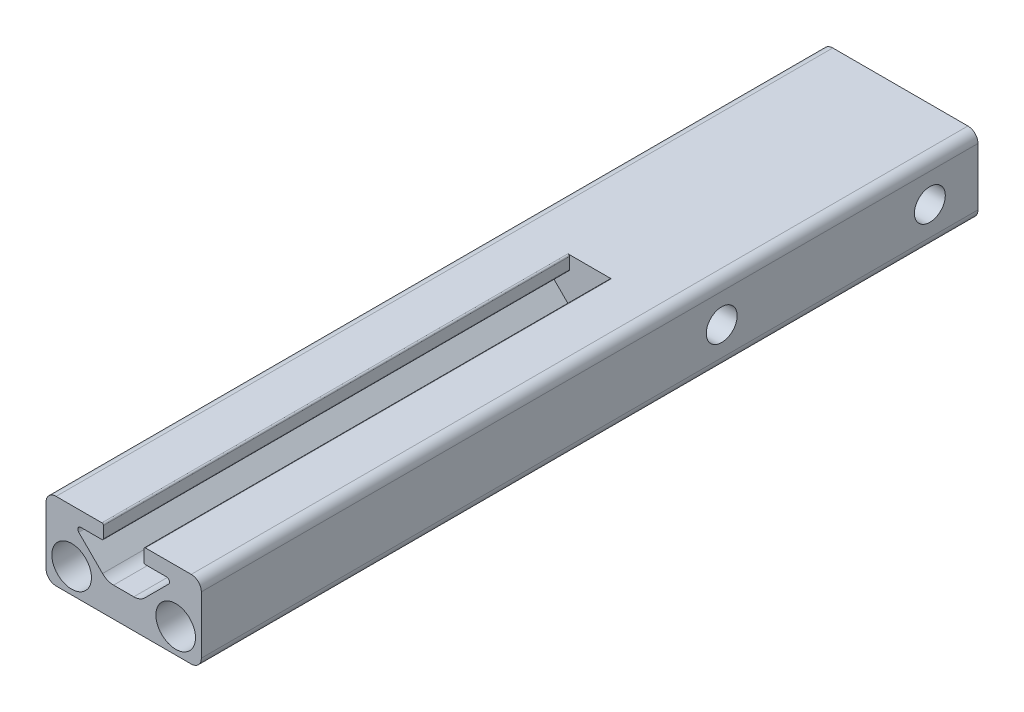
from build123d import *

# Parameters (mm, degrees)
SKETCH3_R                  = 3.2385
BOSS_EXTRUDE1_DEPTH        = 38.1
FILLET1_R                  = 0.254
BOSS_EXTRUDE2_DEPTH        = 50.8
F_8_0_199_DIAMETER_HOLE8_D = 5.0546
LPATTERN1_COUNT            = 2
LPATTERN1_PITCH            = 34.036


with BuildPart() as part:
    # Sketch3 → Boss-Extrude1 (new body, symmetric)
    with BuildSketch(Plane.XY):
        with BuildLine():
            Line((-11.049, 12.7), (-3.302, 12.7))
            Line((-3.302, 12.7), (-3.302, 10.328863887))
            Line((-3.302, 10.328863887), (-6.985, 10.328863887))
            ThreePointArc((-6.985, 10.328863887), (-7.454330803, 10.01526707), (-7.344210245, 9.461653642))
            Line((-7.344210245, 9.461653642), (-3.452505379, 5.569948776))
            ThreePointArc((-3.452505379, 5.569948776), (-2.628470073, 5.019345987), (-1.656454155, 4.826))
            Line((-1.656454155, 4.826), (1.656454155, 4.826))
            ThreePointArc((1.656454155, 4.826), (2.628470073, 5.019345987), (3.452505379, 5.569948776))
            Line((3.452505379, 5.569948776), (7.344210245, 9.461653642))
            ThreePointArc((7.344210245, 9.461653642), (7.454330803, 10.01526707), (6.985, 10.328863887))
            Line((6.985, 10.328863887), (3.302, 10.328863887))
            Line((3.302, 10.328863887), (3.302, 12.7))
            Line((3.302, 12.7), (11.049, 12.7))
            ThreePointArc((11.049, 12.7), (12.216433296, 12.216433296), (12.7, 11.049))
            Line((12.7, 11.049), (12.7, 1.651))
            ThreePointArc((12.7, 1.651), (12.216433296, 0.483566704), (11.049, 0))
            Line((11.049, 0), (-11.049, 0))
            ThreePointArc((-11.049, 0), (-12.216433296, 0.483566704), (-12.7, 1.651))
            Line((-12.7, 1.651), (-12.7, 11.049))
            ThreePointArc((-12.7, 11.049), (-12.216433296, 12.216433296), (-11.049, 12.7))
        make_face()
        with Locations((8.509, 4.064)):
            Circle(SKETCH3_R, mode=Mode.SUBTRACT)
        with Locations((-8.509, 4.064)):
            Circle(SKETCH3_R, mode=Mode.SUBTRACT)
    extrude(amount=BOSS_EXTRUDE1_DEPTH, both=True)

    # Fillet1
    fillet1_edges = [part.edges().sort_by_distance(p)[0] for p in [
        (-3.302, 12.7, 0),
        (-3.302, 10.328863887, 0),
        (3.302, 10.328863887, 0),
        (3.302, 12.7, 0),
    ]]
    fillet(fillet1_edges, radius=FILLET1_R)

    # Sketch4 → Boss-Extrude2 (add)
    with BuildSketch(Plane(origin=(0, 0, -38.1), x_dir=(-1, 0, 0), z_dir=(0, 0, -1))):
        with BuildLine():
            Line((3.556, 12.7), (-11.049, 12.7))
            ThreePointArc((-11.049, 12.7), (-12.216433296, 12.216433296), (-12.7, 11.049))
            Line((-12.7, 11.049), (-12.7, 1.651))
            ThreePointArc((-12.7, 1.651), (-12.216433296, 0.483566704), (-11.049, 0))
            Line((-11.049, 0), (11.049, 0))
            ThreePointArc((11.049, 0), (12.216433296, 0.483566704), (12.7, 1.651))
            Line((12.7, 1.651), (12.7, 11.049))
            ThreePointArc((12.7, 11.049), (12.216433296, 12.216433296), (11.049, 12.7))
            Line((11.049, 12.7), (3.556, 12.7))
        make_face()
    extrude(amount=BOSS_EXTRUDE2_DEPTH)

    # #8 (0.199) Diameter Hole8 (through all)
    with Locations(Plane(origin=(12.7, 0, 0), x_dir=(0, 0, -1), z_dir=(1, 0, 0))):
        with Locations((81.026, 6.35)):
            f_8_0_199_diameter_hole8 = Hole(F_8_0_199_DIAMETER_HOLE8_D / 2)

    # LPattern1: #8 (0.199) Diameter Hole8 ×2
    with Locations(*[(0, 0, i * LPATTERN1_PITCH) for i in range(1, LPATTERN1_COUNT)]):
        add(f_8_0_199_diameter_hole8, mode=Mode.SUBTRACT)


solid = part.part
